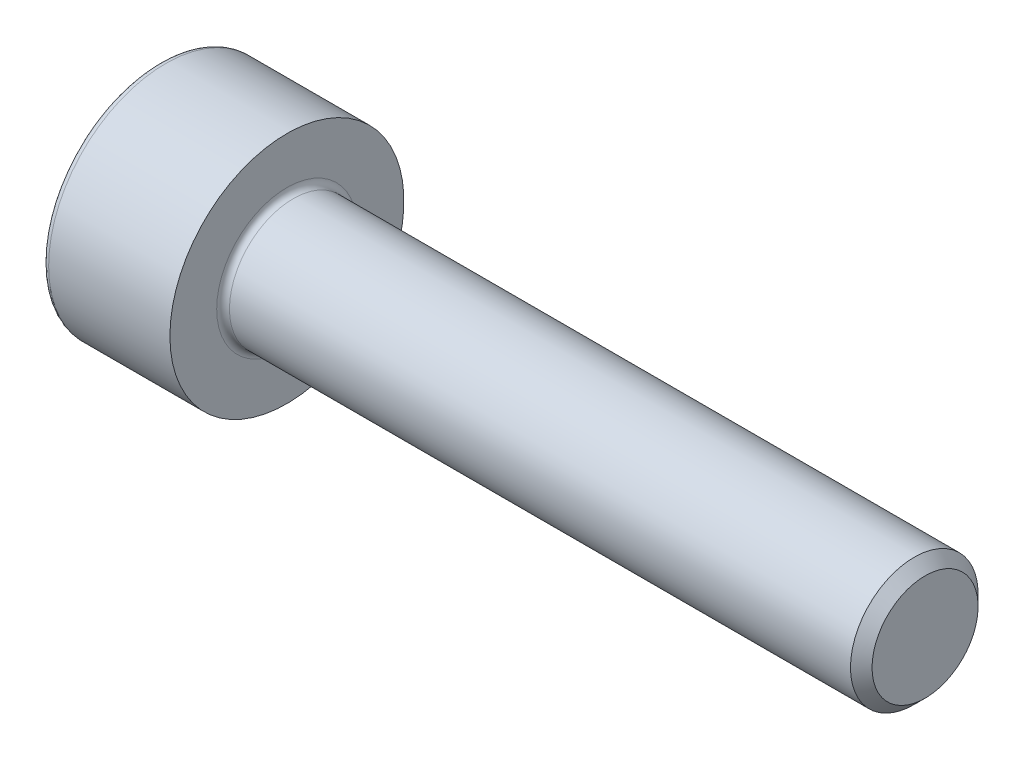
from build123d import *

# Parameters (mm, degrees)
CUT_EXTRUDE1_DEPTH = 1.3


with BuildPart() as part:
    # Sketch1 → Revolve1 (revolve)
    with BuildSketch(Plane.XY):
        with BuildLine():
            Line((14.7465, 1.5), (0.15, 1.5))
            ThreePointArc((0.15, 1.5), (0.043933983, 1.543933983), (0, 1.65))
            Line((0, 1.65), (0, 2.75))
            Line((0, 2.75), (-2.85, 2.75))
            ThreePointArc((-2.85, 2.75), (-2.956066017, 2.706066017), (-3, 2.6))
            Line((-3, 2.6), (-3, 0))
            Line((-3, 0), (15, 0))
            Line((15, 0), (15, 1.2465))
            Line((15, 1.2465), (14.7465, 1.5))
        make_face()
    revolve(axis=Axis((-3, 0, 0), (1, 0, 0)))

    # Sketch2 → Cut-Extrude1 (cut)
    with BuildSketch(Plane.ZY.offset(3)):
        Polygon((1.28, 0.739008345), (0, 1.478016689), (-1.28, 0.739008345), (-1.28, -0.739008345), (0, -1.478016689), (1.28, -0.739008345), align=None)
    extrude(amount=-CUT_EXTRUDE1_DEPTH, mode=Mode.SUBTRACT)


solid = part.part
